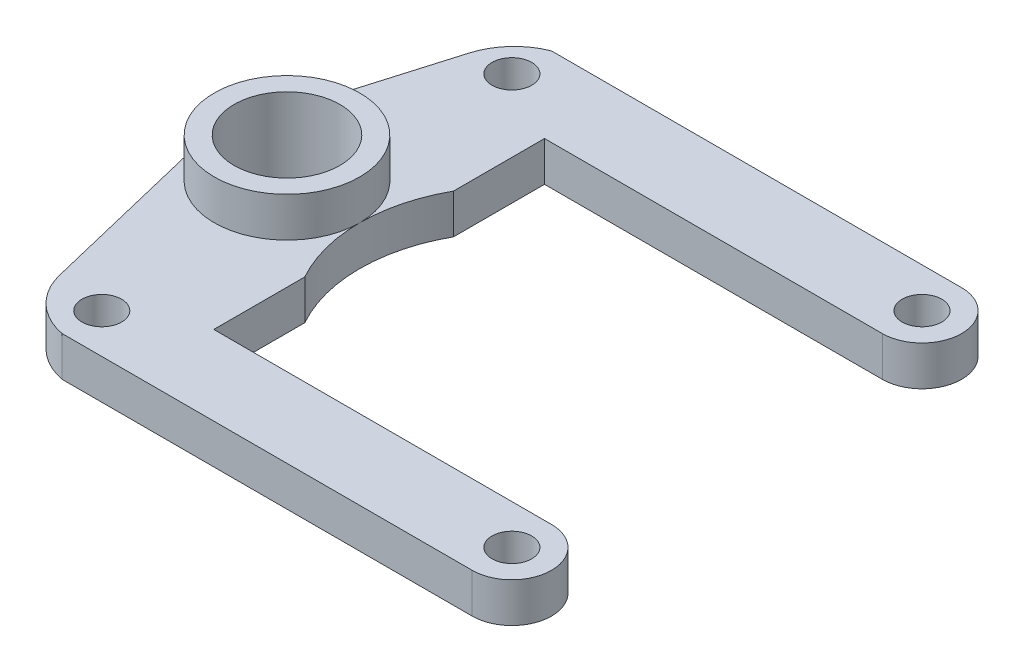
from build123d import *

# Parameters (mm, degrees)
SKETCH1_R           = 1.5
SKETCH1_R_2         = 4
BOSS_EXTRUDE1_DEPTH = 3
SKETCH2_R           = 11.5
CUT_EXTRUDE2_DEPTH  = 3
SKETCH3_R           = 5.5
SKETCH3_R_2         = 4
BOSS_EXTRUDE2_DEPTH = 3


with BuildPart() as part:
    # Sketch1 → Boss-Extrude1 (new body)
    with BuildSketch(Plane(origin=(0, 0, 0), x_dir=(1, 0, 0), z_dir=(0, 1, 0))):
        with BuildLine():
            Line((31, -3), (0, -3))
            ThreePointArc((0, -3), (-2.5078369, -1.708002816), (-3.917144015, 0.735837624))
            Line((-3.917144015, 0.735837624), (-7.484880003, 15.5))
            Line((-7.484880003, 15.5), (-2.974611695, 30.760315636))
            ThreePointArc((-2.974611695, 30.760315636), (-1.862648685, 32.724789909), (0, 34))
            Line((0, 34), (31, 34))
            ThreePointArc((31, 34), (34, 31), (31, 28))
            Line((31, 28), (5.467072376, 28))
            Line((5.467072376, 28), (5.467072376, 3))
            Line((5.467072376, 3), (31, 3))
            ThreePointArc((31, 3), (34, 0), (31, -3))
        make_face()
        with Locations((0, 31)):
            Circle(SKETCH1_R, mode=Mode.SUBTRACT)
        with Locations((31, 31)):
            Circle(SKETCH1_R, mode=Mode.SUBTRACT)
        with Locations((31, 0)):
            Circle(SKETCH1_R, mode=Mode.SUBTRACT)
        Circle(SKETCH1_R, mode=Mode.SUBTRACT)
        with Locations((-1.5, 15.5)):
            Circle(SKETCH1_R_2, mode=Mode.SUBTRACT)
    extrude(amount=BOSS_EXTRUDE1_DEPTH)

    # Sketch2 → Cut-Extrude2 (cut)
    with BuildSketch(Plane(origin=(0, 3, 0), x_dir=(1, 0, 0), z_dir=(0, 1, 0))):
        with Locations((15.5, 15.5)):
            Circle(SKETCH2_R)
    extrude(amount=-CUT_EXTRUDE2_DEPTH, mode=Mode.SUBTRACT)

    # Sketch3 → Boss-Extrude2 (add)
    with BuildSketch(Plane(origin=(0, 3, 0), x_dir=(1, 0, 0), z_dir=(0, 1, 0))):
        with Locations((-1.5, 15.5)):
            Circle(SKETCH3_R)
        with Locations((-1.5, 15.5)):
            Circle(SKETCH3_R_2, mode=Mode.SUBTRACT)
    extrude(amount=BOSS_EXTRUDE2_DEPTH)


solid = part.part
